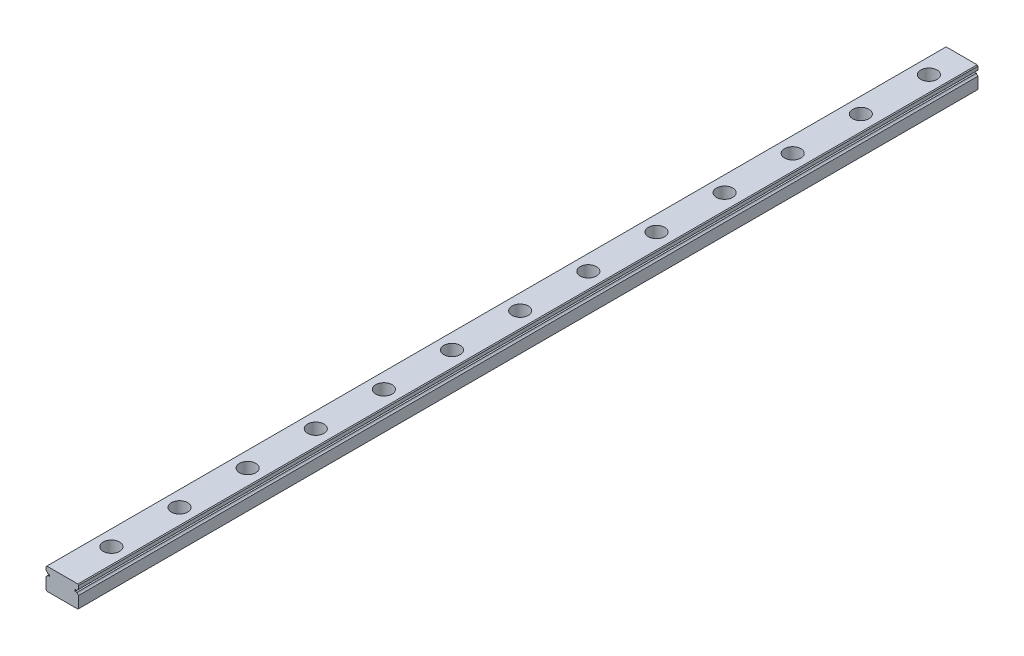
from build123d import *

# Parameters (mm, degrees)
EXTRUDE_1_DEPTH        = 330
SKETCH_2_R             = 3
SKETCH_2_R_2           = 1.75
CUT_EXTRUDE_1_DEPTH    = 4.5
SKETCH_2_2_R           = 1.75
CUT_EXTRUDE_2_DEPTH    = 331.151480384
PATTERN_LINEAR_1_COUNT = 16
PATTERN_LINEAR_1_PITCH = 25


with BuildPart() as part:
    # Эскиз1 → Бобышка-Вытянуть1 (new body)
    with BuildSketch(Plane.XY):
        with BuildLine():
            Line((-6, 3.7), (-5.7, 4))
            Line((-5.7, 4), (5.7, 4))
            Line((5.7, 4), (6, 3.7))
            Line((6, 3.7), (6, 2.451013544))
            ThreePointArc((6, 2.451013544), (5.597935912, 2.202976267), (5.354599002, 1.798050138))
            Line((5.354599002, 1.798050138), (4.643514056, 1.798050138))
            Line((4.643514056, 1.798050138), (4.643514056, 1.201949862))
            Line((4.643514056, 1.201949862), (5.354599002, 1.201949862))
            ThreePointArc((5.354599002, 1.201949862), (5.597935912, 0.797023733), (6, 0.548986456))
            Line((6, 0.548986456), (6, -3.7))
            Line((6, -3.7), (5.7, -4))
            Line((5.7, -4), (-5.7, -4))
            Line((-5.7, -4), (-6, -3.7))
            Line((-6, -3.7), (-6, 0.548986456))
            ThreePointArc((-6, 0.548986456), (-5.597935912, 0.797023733), (-5.354599002, 1.201949862))
            Line((-5.354599002, 1.201949862), (-4.643514056, 1.201949862))
            Line((-4.643514056, 1.201949862), (-4.643514056, 1.798050138))
            Line((-4.643514056, 1.798050138), (-5.354599002, 1.798050138))
            ThreePointArc((-5.354599002, 1.798050138), (-5.597935912, 2.202976267), (-6, 2.451013544))
            Line((-6, 2.451013544), (-6, 3.7))
        make_face()
    extrude(amount=EXTRUDE_1_DEPTH)

    # Эскиз2 → Вырез-Вытянуть1 (cut)
    with BuildSketch(Plane(origin=(0, 4, 0), x_dir=(1, 0, 0), z_dir=(0, 1, 0))):
        with Locations((0, -12)):
            Circle(SKETCH_2_R)
        with Locations((0, -12)):
            Circle(SKETCH_2_R_2, mode=Mode.SUBTRACT)
    cut_extrude_1 = extrude(amount=-CUT_EXTRUDE_1_DEPTH, mode=Mode.SUBTRACT)

    # Эскиз2<2> → Вырез-Вытянуть2 (cut, through all)
    with BuildSketch(Plane(origin=(0, 4, 0), x_dir=(1, 0, 0), z_dir=(0, 1, 0))):
        with Locations((0, -12)):
            Circle(SKETCH_2_2_R)
    cut_extrude_2 = extrude(amount=-CUT_EXTRUDE_2_DEPTH, mode=Mode.SUBTRACT)

    # Линейный массив1: Вырез-Вытянуть1, Вырез-Вытянуть2 ×16
    with Locations(*[(0, 0, i * PATTERN_LINEAR_1_PITCH) for i in range(1, PATTERN_LINEAR_1_COUNT)]):
        add(cut_extrude_1, mode=Mode.SUBTRACT)
        add(cut_extrude_2, mode=Mode.SUBTRACT)


solid = part.part
